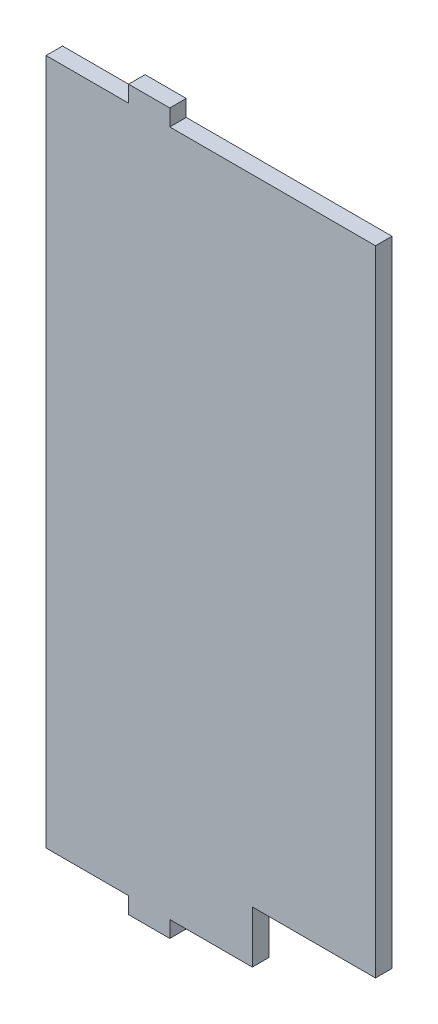
from build123d import *

# Parameters (mm, degrees)
ESQUISSE1_W             = 120
ESQUISSE1_H             = 250
BOSS_EXTRU_1_DEPTH      = 6
ESQUISSE2_W             = 15
ESQUISSE2_H             = 6
BOSS_EXTRU_3_DEPTH      = 6
ESQUISSE3_W             = 44.86
ESQUISSE3_H             = 19
ENL_V_MAT_EXTRU_1_DEPTH = 6


with BuildPart() as part:
    # Esquisse1 → Boss.-Extru.1 (new body)
    with BuildSketch(Plane.XY):
        with Locations((-137.920305677, 0)):
            Rectangle(ESQUISSE1_W, ESQUISSE1_H)
    extrude(amount=BOSS_EXTRU_1_DEPTH)

    # Esquisse2 → Boss.-Extru.3 (add)
    with BuildSketch(Plane.XY.offset(6)):
        with Locations((-160.350305677, -128)):
            Rectangle(ESQUISSE2_W, ESQUISSE2_H)
        with Locations((-160.350305677, 128)):
            Rectangle(ESQUISSE2_W, ESQUISSE2_H)
    extrude(amount=-BOSS_EXTRU_3_DEPTH)

    # Esquisse3 → Enlèv. mat.-Extru.1 (cut)
    with BuildSketch(Plane.XY.offset(6)):
        with Locations((-100.350305677, -115.5)):
            Rectangle(ESQUISSE3_W, ESQUISSE3_H)
    extrude(amount=-ENL_V_MAT_EXTRU_1_DEPTH, mode=Mode.SUBTRACT)


solid = part.part
